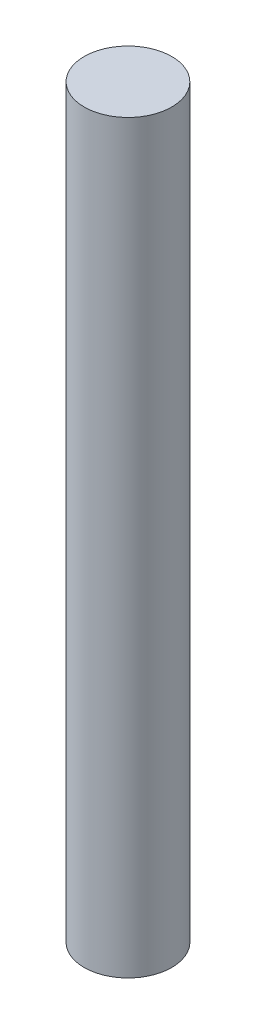
from build123d import *

# Parameters (mm, degrees)
CROQUIS1_R              = 5.975
SALIENTE_EXTRUIR1_DEPTH = 101.72


with BuildPart() as part:
    # Croquis1 → Saliente-Extruir1 (new body)
    with BuildSketch(Plane(origin=(0, 0, 0), x_dir=(1, 0, 0), z_dir=(0, 1, 0))):
        Circle(CROQUIS1_R)
    extrude(amount=SALIENTE_EXTRUIR1_DEPTH)


solid = part.part
